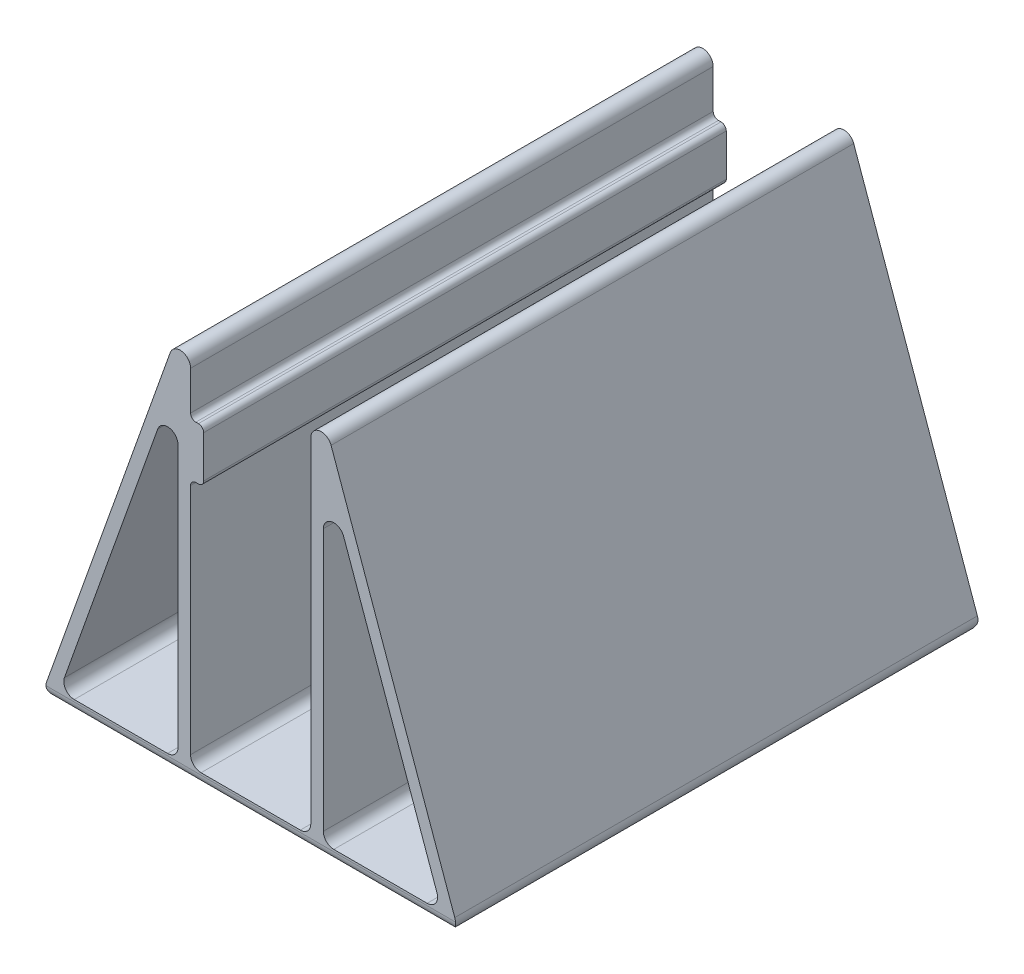
from build123d import *

# Parameters (mm, degrees)
BOSS_EXTRU_1_DEPTH = 100
CONG_1_R           = 2
CONG_2_R           = 1


with BuildPart() as part:
    # Esquisse1 → Boss.-Extru.1 (new body)
    with BuildSketch(Plane.XY):
        Polygon((-11.5, 2.4), (11.5, 2.4), (11.5, 80), (40, 0), (-40, 0), (-11.5, 80), (-11.5, 60), (-9, 60), (-9, 50), (-11.5, 50), align=None)
        Polygon((13.9, 66.111581736), (13.9, 2.4), (36.597250994, 2.4), align=None, mode=Mode.SUBTRACT)
        Polygon((-13.9, 2.4), (-36.597250994, 2.4), (-13.9, 66.111581736), align=None, mode=Mode.SUBTRACT)
    extrude(amount=BOSS_EXTRU_1_DEPTH)

    # Congé1
    cong_1_edges = [part.edges().sort_by_distance(p)[0] for p in [
        (0, 0, 0),
        (11.5, 80, 50),
        (40, 0, 50),
        (-40, 0, 50),
        (-11.5, 80, 50),
        (-11.5, 2.4, 50),
        (11.5, 2.4, 50),
        (36.597250994, 2.4, 50),
        (13.9, 66.111581736, 50),
        (13.9, 2.4, 50),
        (0, 0, 100),
        (-13.9, 2.4, 50),
        (-13.9, 66.111581736, 50),
        (-36.597250994, 2.4, 50),
    ]]
    fillet(cong_1_edges, radius=CONG_1_R)

    # Congé2
    cong_2_edges = [part.edges().sort_by_distance(p)[0] for p in [
        (-11.5, 60, 50),
        (-9, 60, 50),
        (-9, 50, 50),
        (-11.5, 50, 50),
    ]]
    fillet(cong_2_edges, radius=CONG_2_R)


solid = part.part
